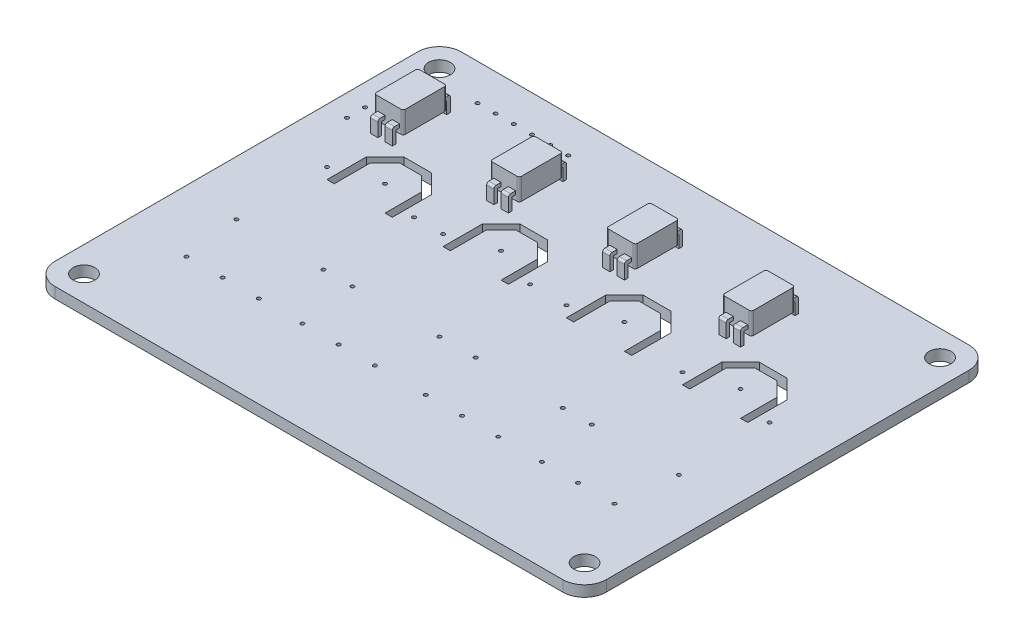
from build123d import *

# Parameters (mm, degrees)
IZIM1_R                           = 1.5
IZIM1_R_2                         = 0.25
Y_KSEKLIK_EKSTR_ZYON1_DEPTH       = 1.5
IZIM2_R                           = 0.25
KES_EKSTR_ZYON1_DEPTH             = 10
Y_KSEKLIK_EKSTR_ZYON2_DEPTH       = 3
Y_KSEKLIK_EKSTR_ZYON2_2_DEPTH     = 3
Y_KSEKLIK_EKSTR_ZYON2_3_DEPTH     = 3
Y_KSEKLIK_EKSTR_ZYON2_4_DEPTH     = 3
Y_KSEKLIK_EKSTR_ZYON3_DEPTH       = 0.5
Y_KSEKLIK_EKSTR_ZYON3_DEPTH_BACK  = 0.5
Y_KSEKLIK_EKSTR_ZYON4_DEPTH       = 0.5
Y_KSEKLIK_EKSTR_ZYON4_DEPTH_BACK  = 0.5
Y_KSEKLIK_EKSTR_ZYON5_DEPTH       = 0.5
Y_KSEKLIK_EKSTR_ZYON5_DEPTH_BACK  = 0.5
Y_KSEKLIK_EKSTR_ZYON6_DEPTH       = 0.5
Y_KSEKLIK_EKSTR_ZYON6_DEPTH_BACK  = 0.5
Y_KSEKLIK_EKSTR_ZYON7_DEPTH       = 0.5
Y_KSEKLIK_EKSTR_ZYON7_DEPTH_BACK  = 0.5
Y_KSEKLIK_EKSTR_ZYON8_DEPTH       = 0.5
Y_KSEKLIK_EKSTR_ZYON8_DEPTH_BACK  = 0.5
Y_KSEKLIK_EKSTR_ZYON9_DEPTH       = 0.5
Y_KSEKLIK_EKSTR_ZYON9_DEPTH_BACK  = 0.5
Y_KSEKLIK_EKSTR_ZYON10_DEPTH      = 0.5
Y_KSEKLIK_EKSTR_ZYON10_DEPTH_BACK = 0.5
KES_EKSTR_ZYON2_DEPTH             = 10


with BuildPart() as part:
    # Çizim1 → Yükseklik-Ekstrüzyon1 (new body)
    with BuildSketch(Plane(origin=(0, 0, 0), x_dir=(1, 0, 0), z_dir=(0, 1, 0))):
        with BuildLine():
            Line((-35, 28), (35, 28))
            ThreePointArc((35, 28), (37.121320344, 27.121320344), (38, 25))
            Line((38, 25), (38, -25))
            ThreePointArc((38, -25), (37.121320344, -27.121320344), (35, -28))
            Line((35, -28), (-35, -28))
            ThreePointArc((-35, -28), (-37.121320344, -27.121320344), (-38, -25))
            Line((-38, -25), (-38, 25))
            ThreePointArc((-38, 25), (-37.121320344, 27.121320344), (-35, 28))
        make_face()
        with Locations((-34.5, 24.5)):
            Circle(IZIM1_R, mode=Mode.SUBTRACT)
        with Locations((34.5, 24.5)):
            Circle(IZIM1_R, mode=Mode.SUBTRACT)
        with Locations((34.5, -24.5)):
            Circle(IZIM1_R, mode=Mode.SUBTRACT)
        with Locations((-34.5, -24.5)):
            Circle(IZIM1_R, mode=Mode.SUBTRACT)
        with Locations((-8.5, 7)):
            Circle(IZIM1_R_2, mode=Mode.SUBTRACT)
        with Locations((-24.5, 7)):
            Circle(IZIM1_R_2, mode=Mode.SUBTRACT)
        with Locations((8.5, 7)):
            Circle(IZIM1_R_2, mode=Mode.SUBTRACT)
        with Locations((24.5, 7)):
            Circle(IZIM1_R_2, mode=Mode.SUBTRACT)
        with Locations((-14.5, 5)):
            Circle(IZIM1_R_2, mode=Mode.SUBTRACT)
        with Locations((-18.5, 5)):
            Circle(IZIM1_R_2, mode=Mode.SUBTRACT)
        with Locations((-14.5, -7.5)):
            Circle(IZIM1_R_2, mode=Mode.SUBTRACT)
        with Locations((-18.5, -7.5)):
            Circle(IZIM1_R_2, mode=Mode.SUBTRACT)
        with Locations((-2.5, -7.5)):
            Circle(IZIM1_R_2, mode=Mode.SUBTRACT)
        with Locations((-2.5, 5)):
            Circle(IZIM1_R_2, mode=Mode.SUBTRACT)
        with Locations((-30.5, 5)):
            Circle(IZIM1_R_2, mode=Mode.SUBTRACT)
        with Locations((-30.5, -7.5)):
            Circle(IZIM1_R_2, mode=Mode.SUBTRACT)
        with Locations((2.5, -7.5)):
            Circle(IZIM1_R_2, mode=Mode.SUBTRACT)
        with Locations((14.5, -7.5)):
            Circle(IZIM1_R_2, mode=Mode.SUBTRACT)
        with Locations((18.5, -7.5)):
            Circle(IZIM1_R_2, mode=Mode.SUBTRACT)
        with Locations((30.5, -7.5)):
            Circle(IZIM1_R_2, mode=Mode.SUBTRACT)
        with Locations((30.5, 5)):
            Circle(IZIM1_R_2, mode=Mode.SUBTRACT)
        with Locations((18.5, 5)):
            Circle(IZIM1_R_2, mode=Mode.SUBTRACT)
        with Locations((2.5, 5)):
            Circle(IZIM1_R_2, mode=Mode.SUBTRACT)
        with Locations((-24.5, -15.39)):
            Circle(IZIM1_R_2, mode=Mode.SUBTRACT)
        with Locations((-19.5, -15.39)):
            Circle(IZIM1_R_2, mode=Mode.SUBTRACT)
        with Locations((-29.5, -15.39)):
            Circle(IZIM1_R_2, mode=Mode.SUBTRACT)
        with Locations((-13.5, -15.39)):
            Circle(IZIM1_R_2, mode=Mode.SUBTRACT)
        with Locations((-8.5, -15.39)):
            Circle(IZIM1_R_2, mode=Mode.SUBTRACT)
        with Locations((-3.5, -15.39)):
            Circle(IZIM1_R_2, mode=Mode.SUBTRACT)
        with Locations((3.5, -15.39)):
            Circle(IZIM1_R_2, mode=Mode.SUBTRACT)
        with Locations((8.5, -15.39)):
            Circle(IZIM1_R_2, mode=Mode.SUBTRACT)
        with Locations((13.5, -15.39)):
            Circle(IZIM1_R_2, mode=Mode.SUBTRACT)
        with Locations((19.5, -15.39)):
            Circle(IZIM1_R_2, mode=Mode.SUBTRACT)
        with Locations((24.5, -15.39)):
            Circle(IZIM1_R_2, mode=Mode.SUBTRACT)
        with Locations((29.5, -15.39)):
            Circle(IZIM1_R_2, mode=Mode.SUBTRACT)
    extrude(amount=Y_KSEKLIK_EKSTR_ZYON1_DEPTH)

    # Çizim2 → Kes-Ekstrüzyon1 (cut)
    with BuildSketch(Plane(origin=(0, 1.5, 0), x_dir=(1, 0, 0), z_dir=(0, 1, 0))):
        with Locations((-22.75, 23)):
            Circle(IZIM2_R)
        with Locations((-25.25, 23)):
            Circle(IZIM2_R)
        with Locations((-27.75, 23)):
            Circle(IZIM2_R)
        with Locations((-20.25, 23)):
            Circle(IZIM2_R)
        with Locations((-17.75, 23)):
            Circle(IZIM2_R)
        with Locations((-15.25, 23)):
            Circle(IZIM2_R)
        with Locations((-35, 14.75)):
            Circle(IZIM2_R)
        with Locations((-35, 12.25)):
            Circle(IZIM2_R)
    extrude(amount=-KES_EKSTR_ZYON1_DEPTH, mode=Mode.SUBTRACT)



with BuildPart() as body_2:
    # Çizim3 → Yükseklik-Ekstrüzyon2 (new body)
    with BuildSketch(Plane(origin=(0, 2.5, 0), x_dir=(1, 0, 0), z_dir=(0, 1, 0))):
        with BuildLine():
            Line((-31.7, 19), (-28.3, 19))
            ThreePointArc((-28.3, 19), (-28.087867966, 18.912132034), (-28, 18.7))
            Line((-28, 18.7), (-28, 13.3))
            ThreePointArc((-28, 13.3), (-28.087867966, 13.087867966), (-28.3, 13))
            Line((-28.3, 13), (-31.7, 13))
            ThreePointArc((-31.7, 13), (-31.912132034, 13.087867966), (-32, 13.3))
            Line((-32, 13.3), (-32, 18.7))
            ThreePointArc((-32, 18.7), (-31.912132034, 18.912132034), (-31.7, 19))
        make_face()
    extrude(amount=Y_KSEKLIK_EKSTR_ZYON2_DEPTH)


with BuildPart() as body_3:
    # Çizim3 → Y_kseklik-Ekstr_zyon2 2 (new body)
    with BuildSketch(Plane(origin=(0, 2.5, 0), x_dir=(1, 0, 0), z_dir=(0, 1, 0))):
        with BuildLine():
            Line((-12.3, 13), (-15.7, 13))
            ThreePointArc((-15.7, 13), (-15.912132034, 13.087867966), (-16, 13.3))
            Line((-16, 13.3), (-16, 18.7))
            ThreePointArc((-16, 18.7), (-15.912132034, 18.912132034), (-15.7, 19))
            Line((-15.7, 19), (-12.3, 19))
            ThreePointArc((-12.3, 19), (-12.087867966, 18.912132034), (-12, 18.7))
            Line((-12, 18.7), (-12, 13.3))
            ThreePointArc((-12, 13.3), (-12.087867966, 13.087867966), (-12.3, 13))
        make_face()
    extrude(amount=Y_KSEKLIK_EKSTR_ZYON2_2_DEPTH)


with BuildPart() as body_4:
    # Çizim3 → Y_kseklik-Ekstr_zyon2 3 (new body)
    with BuildSketch(Plane(origin=(0, 2.5, 0), x_dir=(1, 0, 0), z_dir=(0, 1, 0))):
        with BuildLine():
            Line((0, 18.7), (0, 13.3))
            ThreePointArc((0, 13.3), (0.087867966, 13.087867966), (0.3, 13))
            Line((0.3, 13), (3.7, 13))
            ThreePointArc((3.7, 13), (3.912132034, 13.087867966), (4, 13.3))
            Line((4, 13.3), (4, 18.7))
            ThreePointArc((4, 18.7), (3.912132034, 18.912132034), (3.7, 19))
            Line((3.7, 19), (0.3, 19))
            ThreePointArc((0.3, 19), (0.087867966, 18.912132034), (0, 18.7))
        make_face()
    extrude(amount=Y_KSEKLIK_EKSTR_ZYON2_3_DEPTH)


with BuildPart() as body_5:
    # Çizim3 → Y_kseklik-Ekstr_zyon2 4 (new body)
    with BuildSketch(Plane(origin=(0, 2.5, 0), x_dir=(1, 0, 0), z_dir=(0, 1, 0))):
        with BuildLine():
            Line((19.7, 13), (16.3, 13))
            ThreePointArc((16.3, 13), (16.087867966, 13.087867966), (16, 13.3))
            Line((16, 13.3), (16, 18.7))
            ThreePointArc((16, 18.7), (16.087867966, 18.912132034), (16.3, 19))
            Line((16.3, 19), (19.7, 19))
            ThreePointArc((19.7, 19), (19.912132034, 18.912132034), (20, 18.7))
            Line((20, 18.7), (20, 13.3))
            ThreePointArc((20, 13.3), (19.912132034, 13.087867966), (19.7, 13))
        make_face()
    extrude(amount=Y_KSEKLIK_EKSTR_ZYON2_4_DEPTH)


with BuildPart() as part_1:
    add(part.part)

    add(body_2.part)  # Yükseklik-Ekstrüzyon3 merges body 2
    # Çizim4 → Yükseklik-Ekstrüzyon3 (add, two sides)
    with BuildSketch(Plane.ZY.offset(31)) as y_kseklik_ekstr_zyon3_sk:
        with BuildLine():
            Line((-19.5, 0.834884131), (-19.5, 3.166951183))
            Line((-19.5, 3.166951183), (-12.5, 3.166951183))
            Line((-12.5, 3.166951183), (-12.5, 0.834884131))
            Line((-12.5, 0.834884131), (-12, 0.834884131))
            Line((-12, 0.834884131), (-12, 3.366951183))
            ThreePointArc((-12, 3.366951183), (-12.087867966, 3.579083218), (-12.3, 3.666951183))
            Line((-12.3, 3.666951183), (-19.7, 3.666951183))
            ThreePointArc((-19.7, 3.666951183), (-19.912132034, 3.579083218), (-20, 3.366951183))
            Line((-20, 3.366951183), (-20, 0.834884131))
            Line((-20, 0.834884131), (-19.5, 0.834884131))
        make_face()
    extrude(amount=Y_KSEKLIK_EKSTR_ZYON3_DEPTH)
    extrude(y_kseklik_ekstr_zyon3_sk.sketch, amount=-Y_KSEKLIK_EKSTR_ZYON3_DEPTH_BACK)

    # Çizim5 → Yükseklik-Ekstrüzyon4 (add, two sides)
    with BuildSketch(Plane(origin=(-29, 0, 0), x_dir=(0, 0, -1), z_dir=(1, 0, 0))) as y_kseklik_ekstr_zyon4_sk:
        with BuildLine():
            Line((12.5, 1.5), (12.5, 3.166951183))
            Line((12.5, 3.166951183), (19.5, 3.166951183))
            Line((19.5, 3.166951183), (19.5, 1.5))
            Line((19.5, 1.5), (20, 1.5))
            Line((20, 1.5), (20, 3.366951183))
            ThreePointArc((20, 3.366951183), (19.912132034, 3.579083218), (19.7, 3.666951183))
            Line((19.7, 3.666951183), (12.3, 3.666951183))
            ThreePointArc((12.3, 3.666951183), (12.087867966, 3.579083218), (12, 3.366951183))
            Line((12, 3.366951183), (12, 1.5))
            Line((12, 1.5), (12.5, 1.5))
        make_face()
    extrude(amount=Y_KSEKLIK_EKSTR_ZYON4_DEPTH)
    extrude(y_kseklik_ekstr_zyon4_sk.sketch, amount=-Y_KSEKLIK_EKSTR_ZYON4_DEPTH_BACK)


    add(body_3.part)  # Yükseklik-Ekstrüzyon5 merges body 3
    # Çizim6 → Yükseklik-Ekstrüzyon5 (add, two sides)
    with BuildSketch(Plane.ZY.offset(15)) as y_kseklik_ekstr_zyon5_sk:
        with BuildLine():
            Line((-20, 1.5), (-19.5, 1.5))
            Line((-19.5, 1.5), (-19.5, 3.166951183))
            Line((-19.5, 3.166951183), (-12.5, 3.166951183))
            Line((-12.5, 3.166951183), (-12.5, 1.5))
            Line((-12.5, 1.5), (-12, 1.5))
            Line((-12, 1.5), (-12, 3.366951183))
            ThreePointArc((-12, 3.366951183), (-12.087867966, 3.579083218), (-12.3, 3.666951183))
            Line((-12.3, 3.666951183), (-19.7, 3.666951183))
            ThreePointArc((-19.7, 3.666951183), (-19.912132034, 3.579083218), (-20, 3.366951183))
            Line((-20, 3.366951183), (-20, 1.5))
        make_face()
    extrude(amount=Y_KSEKLIK_EKSTR_ZYON5_DEPTH)
    extrude(y_kseklik_ekstr_zyon5_sk.sketch, amount=-Y_KSEKLIK_EKSTR_ZYON5_DEPTH_BACK)

    # Çizim7 → Yükseklik-Ekstrüzyon6 (add, two sides)
    with BuildSketch(Plane(origin=(-13, 0, 0), x_dir=(0, 0, -1), z_dir=(1, 0, 0))) as y_kseklik_ekstr_zyon6_sk:
        with BuildLine():
            Line((12, 1.5), (12.5, 1.5))
            Line((12.5, 1.5), (12.5, 3.166951183))
            Line((12.5, 3.166951183), (19.5, 3.166951183))
            Line((19.5, 3.166951183), (19.5, 1.5))
            Line((19.5, 1.5), (20, 1.5))
            Line((20, 1.5), (20, 3.366951183))
            ThreePointArc((20, 3.366951183), (19.912132034, 3.579083218), (19.7, 3.666951183))
            Line((19.7, 3.666951183), (12.3, 3.666951183))
            ThreePointArc((12.3, 3.666951183), (12.087867966, 3.579083218), (12, 3.366951183))
            Line((12, 3.366951183), (12, 1.5))
        make_face()
    extrude(amount=Y_KSEKLIK_EKSTR_ZYON6_DEPTH)
    extrude(y_kseklik_ekstr_zyon6_sk.sketch, amount=-Y_KSEKLIK_EKSTR_ZYON6_DEPTH_BACK)


    add(body_4.part)  # Yükseklik-Ekstrüzyon7 merges body 4
    # Çizim9 → Yükseklik-Ekstrüzyon7 (add, two sides)
    with BuildSketch(Plane.ZY.offset(-1)) as y_kseklik_ekstr_zyon7_sk:
        with BuildLine():
            Line((-12, 1.5), (-12, 3.366951183))
            ThreePointArc((-12, 3.366951183), (-12.087867966, 3.579083218), (-12.3, 3.666951183))
            Line((-12.3, 3.666951183), (-19.7, 3.666951183))
            ThreePointArc((-19.7, 3.666951183), (-19.912132034, 3.579083218), (-20, 3.366951183))
            Line((-20, 3.366951183), (-20, 1.5))
            Line((-20, 1.5), (-19.5, 1.5))
            Line((-19.5, 1.5), (-19.5, 3.166951183))
            Line((-19.5, 3.166951183), (-12.5, 3.166951183))
            Line((-12.5, 3.166951183), (-12.5, 1.5))
            Line((-12.5, 1.5), (-12, 1.5))
        make_face()
    extrude(amount=Y_KSEKLIK_EKSTR_ZYON7_DEPTH)
    extrude(y_kseklik_ekstr_zyon7_sk.sketch, amount=-Y_KSEKLIK_EKSTR_ZYON7_DEPTH_BACK)

    # Çizim10 → Yükseklik-Ekstrüzyon8 (add, two sides)
    with BuildSketch(Plane(origin=(3, 0, 0), x_dir=(0, 0, -1), z_dir=(1, 0, 0))) as y_kseklik_ekstr_zyon8_sk:
        with BuildLine():
            ThreePointArc((12, 3.366951183), (12.087867966, 3.579083218), (12.3, 3.666951183))
            Line((12.3, 3.666951183), (19.7, 3.666951183))
            ThreePointArc((19.7, 3.666951183), (19.912132034, 3.579083218), (20, 3.366951183))
            Line((20, 3.366951183), (20, 1.5))
            Line((20, 1.5), (19.5, 1.5))
            Line((19.5, 1.5), (19.5, 3.166951183))
            Line((19.5, 3.166951183), (12.5, 3.166951183))
            Line((12.5, 3.166951183), (12.5, 1.5))
            Line((12.5, 1.5), (12, 1.5))
            Line((12, 1.5), (12, 3.366951183))
        make_face()
    extrude(amount=Y_KSEKLIK_EKSTR_ZYON8_DEPTH)
    extrude(y_kseklik_ekstr_zyon8_sk.sketch, amount=-Y_KSEKLIK_EKSTR_ZYON8_DEPTH_BACK)


    add(body_5.part)  # Yükseklik-Ekstrüzyon9 merges body 5
    # Çizim11 → Yükseklik-Ekstrüzyon9 (add, two sides)
    with BuildSketch(Plane.ZY.offset(-17)) as y_kseklik_ekstr_zyon9_sk:
        with BuildLine():
            ThreePointArc((-20, 3.366951183), (-19.912132034, 3.579083218), (-19.7, 3.666951183))
            Line((-19.7, 3.666951183), (-12.3, 3.666951183))
            ThreePointArc((-12.3, 3.666951183), (-12.087867966, 3.579083218), (-12, 3.366951183))
            Line((-12, 3.366951183), (-12, 1.5))
            Line((-12, 1.5), (-12.5, 1.5))
            Line((-12.5, 1.5), (-12.5, 3.166951183))
            Line((-12.5, 3.166951183), (-19.5, 3.166951183))
            Line((-19.5, 3.166951183), (-19.5, 1.5))
            Line((-19.5, 1.5), (-20, 1.5))
            Line((-20, 1.5), (-20, 3.366951183))
        make_face()
    extrude(amount=Y_KSEKLIK_EKSTR_ZYON9_DEPTH)
    extrude(y_kseklik_ekstr_zyon9_sk.sketch, amount=-Y_KSEKLIK_EKSTR_ZYON9_DEPTH_BACK)

    # Çizim12 → Yükseklik-Ekstrüzyon10 (add, two sides)
    with BuildSketch(Plane(origin=(19, 0, 0), x_dir=(0, 0, -1), z_dir=(1, 0, 0))) as y_kseklik_ekstr_zyon10_sk:
        with BuildLine():
            ThreePointArc((12, 3.366951183), (12.087867966, 3.579083218), (12.3, 3.666951183))
            Line((12.3, 3.666951183), (19.7, 3.666951183))
            ThreePointArc((19.7, 3.666951183), (19.912132034, 3.579083218), (20, 3.366951183))
            Line((20, 3.366951183), (20, 1.5))
            Line((20, 1.5), (19.5, 1.5))
            Line((19.5, 1.5), (19.5, 3.166951183))
            Line((19.5, 3.166951183), (12.5, 3.166951183))
            Line((12.5, 3.166951183), (12.5, 1.5))
            Line((12.5, 1.5), (12, 1.5))
            Line((12, 1.5), (12, 3.366951183))
        make_face()
    extrude(amount=Y_KSEKLIK_EKSTR_ZYON10_DEPTH)
    extrude(y_kseklik_ekstr_zyon10_sk.sketch, amount=-Y_KSEKLIK_EKSTR_ZYON10_DEPTH_BACK)

    # Çizim13 → Kes-Ekstrüzyon2 (cut)
    with BuildSketch(Plane(origin=(0, 1.5, 0), x_dir=(1, 0, 0), z_dir=(0, 1, 0))):
        Polygon((-28, 8.5), (-26, 10.5), (-23, 10.5), (-21, 8.5), (-21, 3.5), (-20, 3.5), (-20, 8.914213562), (-22.585786438, 11.5), (-26.414213562, 11.5), (-29, 8.914213562), (-29, 3.5), (-28, 3.5), align=None)
        Polygon((-5, 8.5), (-7, 10.5), (-10, 10.5), (-12, 8.5), (-12, 3.5), (-13, 3.5), (-13, 8.914213562), (-10.414213562, 11.5), (-6.585786438, 11.5), (-4, 8.914213562), (-4, 3.5), (-5, 3.5), align=None)
        Polygon((5, 8.5), (5, 3.5), (4, 3.5), (4, 8.914213562), (6.585786438, 11.5), (10.414213562, 11.5), (13, 8.914213562), (13, 3.5), (12, 3.5), (12, 8.5), (10, 10.5), (7, 10.5), align=None)
        Polygon((28, 8.5), (26, 10.5), (23, 10.5), (21, 8.5), (21, 3.5), (20, 3.5), (20, 8.914213562), (22.585786438, 11.5), (26.414213562, 11.5), (29, 8.914213562), (29, 3.5), (28, 3.5), align=None)
    extrude(amount=-KES_EKSTR_ZYON2_DEPTH, mode=Mode.SUBTRACT)


solid = part_1.part
